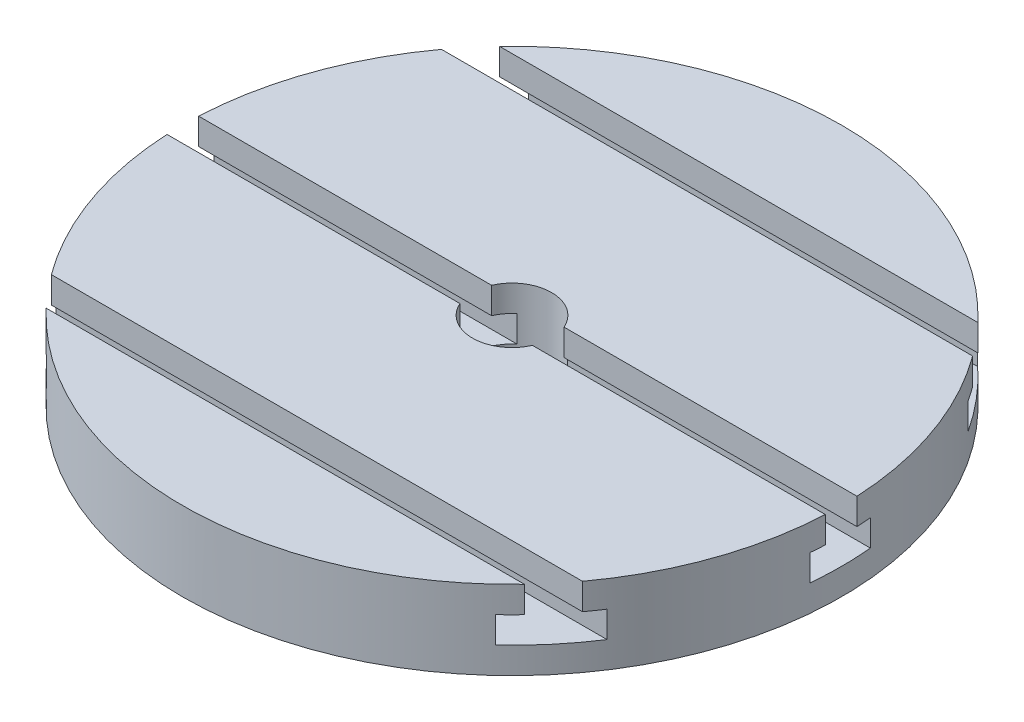
from build123d import *

# Parameters (mm, degrees)
SKETCH_1_W          = 110
SKETCH_1_H          = 30
CUT_EXTRUDE_1_DEPTH = 150


with BuildPart() as part:
    # Эскиз1 → Повернуть1 (revolve)
    with BuildSketch(Plane(origin=(0, 0, 0), x_dir=(0, 0, -1), z_dir=(1, 0, 0))):
        with Locations((70, 15)):
            Rectangle(SKETCH_1_W, SKETCH_1_H)
    revolve(axis=Axis((0, -12.628115938, 0), (0, 1, 0)))

    # Эскиз2 → Вырез-Вытянуть1 (cut, symmetric)
    with BuildSketch(Plane(origin=(0, 0, 0), x_dir=(0, 0, -1), z_dir=(1, 0, 0))):
        Polygon((11.5, 10), (11.5, 20), (6, 20), (6, 30), (-6, 30), (-6, 20), (-11.5, 20), (-11.5, 10), align=None)
        Polygon((68.5, 10), (91.5, 10), (91.5, 20), (86, 20), (86, 30), (74, 30), (74, 20), (68.5, 20), align=None)
        Polygon((-91.5, 10), (-68.5, 10), (-68.5, 20), (-74, 20), (-74, 30), (-86, 30), (-86, 20), (-91.5, 20), align=None)
    extrude(amount=CUT_EXTRUDE_1_DEPTH, both=True, mode=Mode.SUBTRACT)


solid = part.part
